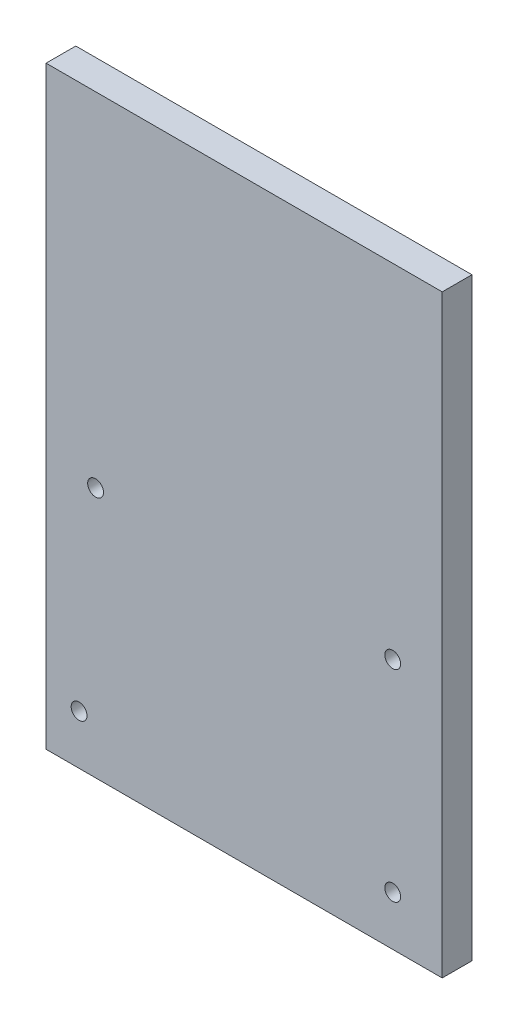
from build123d import *

# Parameters (mm, degrees)
CROQUIS1_W              = 200
CROQUIS1_H              = 300
CROQUIS1_R              = 4
SALIENTE_EXTRUIR1_DEPTH = 15


with BuildPart() as part:
    # Croquis1 → Saliente-Extruir1 (new body)
    with BuildSketch(Plane.XY):
        Rectangle(CROQUIS1_W, CROQUIS1_H)
        with Locations((-75.005, -23.2)):
            Circle(CROQUIS1_R, mode=Mode.SUBTRACT)
        with Locations((75.005, -23.2)):
            Circle(CROQUIS1_R, mode=Mode.SUBTRACT)
        with Locations((75.005, -125)):
            Circle(CROQUIS1_R, mode=Mode.SUBTRACT)
        with Locations((-83.333333333, -125)):
            Circle(CROQUIS1_R, mode=Mode.SUBTRACT)
    extrude(amount=SALIENTE_EXTRUIR1_DEPTH)


solid = part.part
